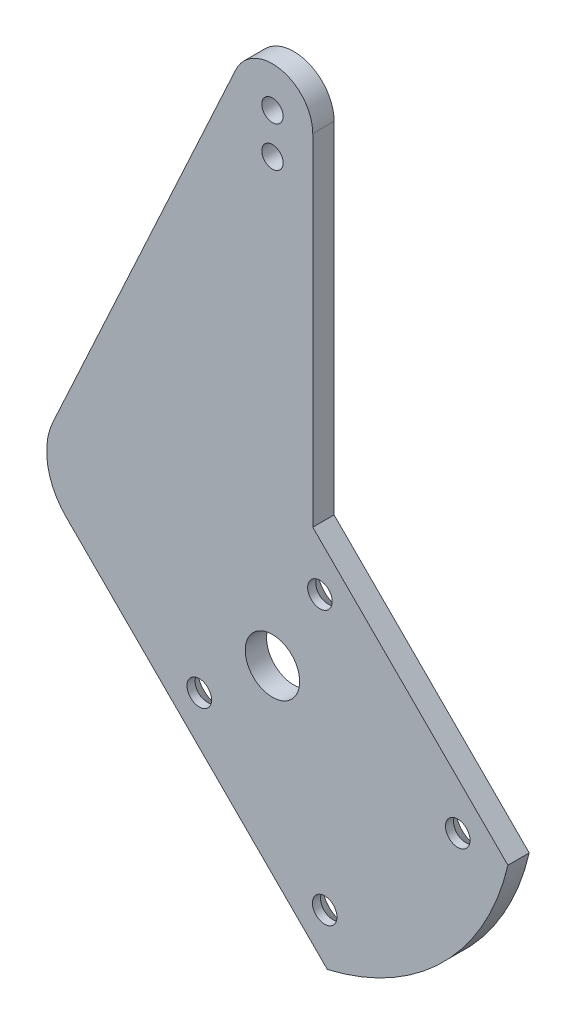
from build123d import *

# Parameters (mm, degrees)
SKETCH2_R                                      = 1.5875
SKETCH2_R_2                                    = 4.05
BOSS_EXTRUDE1_DEPTH                            = 3.175
CSK_FOR_6_FLAT_HEAD_MACHINE_SCREW1_D           = 3.6576
CSK_FOR_6_FLAT_HEAD_MACHINE_SCREW1_DEPTH       = 10.973
CSK_FOR_6_FLAT_HEAD_MACHINE_SCREW1_CSINK_D     = 7.0866
CSK_FOR_6_FLAT_HEAD_MACHINE_SCREW1_CSINK_ANGLE = 82
CSK_FOR_6_FLAT_HEAD_MACHINE_SCREW1_TIP         = 1.0988539
FILLET1_R                                      = 10


with BuildPart() as part:
    # Sketch2 → Boss-Extrude1 (new body)
    with BuildSketch(Plane.XY):
        with BuildLine():
            Line((8.170067778, -35.040125463), (-35.040125463, 8.170067778))
            ThreePointArc((-35.040125463, 8.170067778), (-34.032148119, 11.677897689), (-32.673983585, 15.065563272))
            Line((-32.673983585, 15.065563272), (-5.448690981, 74.111398302))
            ThreePointArc((-5.448690981, 74.111398302), (1.286050954, 77.459627628), (6, 71.599075355))
            Line((6, 71.599075355), (6, 20.870057685))
            Line((6, 20.870057685), (35.040125463, -8.170067778))
            ThreePointArc((35.040125463, -8.170067778), (25.441701987, -25.441701987), (8.170067778, -35.040125463))
        make_face()
        with Locations((0, 71.599075355)):
            Circle(SKETCH2_R, mode=Mode.SUBTRACT)
        with Locations((0, 65.599075355)):
            Circle(SKETCH2_R, mode=Mode.SUBTRACT)
        Circle(SKETCH2_R_2, mode=Mode.SUBTRACT)
    extrude(amount=-BOSS_EXTRUDE1_DEPTH)

    # CSK for _6 Flat Head Machine Screw1
    with Locations(Plane(origin=(0, 0, -3.175), x_dir=(-1, 0, 0), z_dir=(0, 0, -1))):
        with Locations((-7.071067812, 12.727922061), (-27.577164466, -7.778174593), (10.886616003, -8.91237387), (-7.778174593, -27.577164466)):
            CounterSinkHole(CSK_FOR_6_FLAT_HEAD_MACHINE_SCREW1_D / 2, CSK_FOR_6_FLAT_HEAD_MACHINE_SCREW1_CSINK_D / 2, depth=CSK_FOR_6_FLAT_HEAD_MACHINE_SCREW1_DEPTH, counter_sink_angle=CSK_FOR_6_FLAT_HEAD_MACHINE_SCREW1_CSINK_ANGLE)
            with Locations((0, 0, -(CSK_FOR_6_FLAT_HEAD_MACHINE_SCREW1_DEPTH + CSK_FOR_6_FLAT_HEAD_MACHINE_SCREW1_TIP / 2))):  # 118° drill point
                Cone(0, CSK_FOR_6_FLAT_HEAD_MACHINE_SCREW1_D / 2, CSK_FOR_6_FLAT_HEAD_MACHINE_SCREW1_TIP, mode=Mode.SUBTRACT)

    # Fillet1
    fillet1_edges = [part.edges().sort_by_distance(p)[0] for p in [
        (-35.040125463, 8.170067778, -1.5875),
    ]]
    fillet(fillet1_edges, radius=FILLET1_R)


solid = part.part
